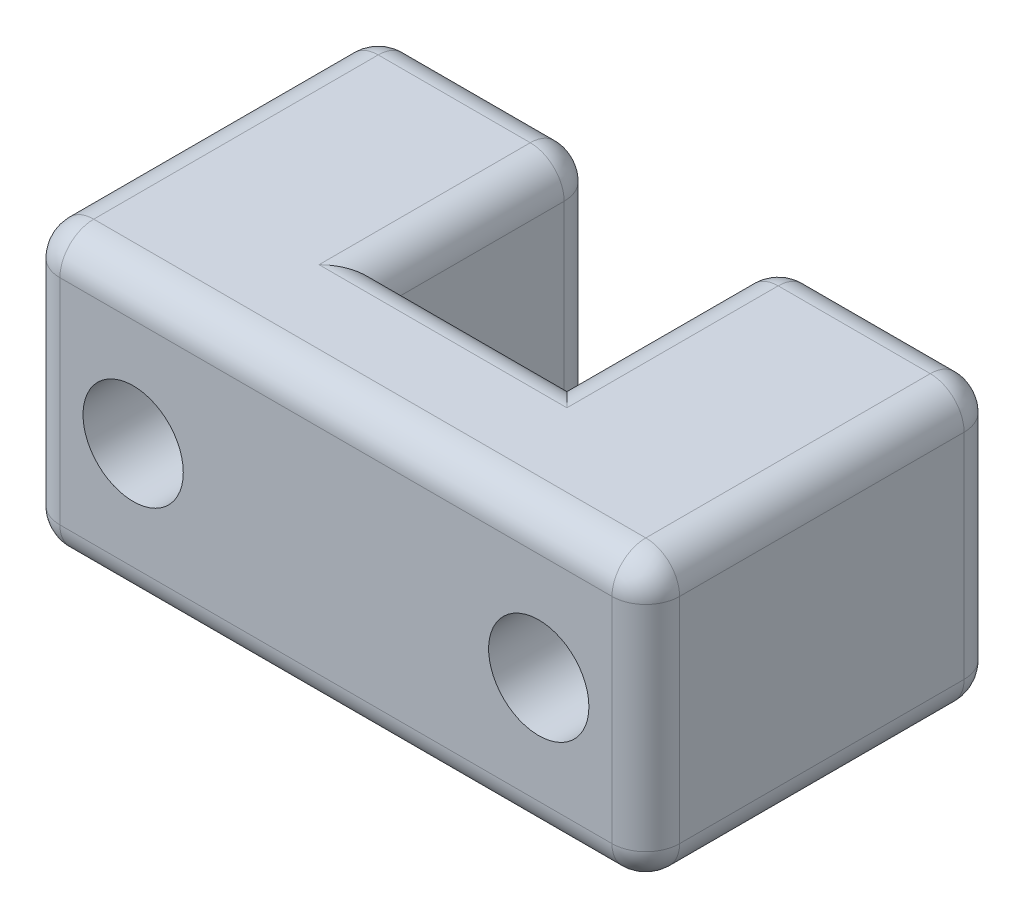
from build123d import *

# Parameters (mm, degrees)
BOSS_EXTRUDE1_DEPTH = 6.35
SKETCH2_R           = 1.1303
CUT_EXTRUDE1_DEPTH  = 7.9375
FILLET1_R           = 0.762


with BuildPart() as part:
    # Sketch1 → Boss-Extrude1 (new body)
    with BuildSketch(Plane(origin=(0, 0, 0), x_dir=(1, 0, 0), z_dir=(0, 1, 0))):
        Polygon((0, 7.9375), (4.953, 7.9375), (4.953, 3.175), (9.017, 3.175), (9.017, 7.9375), (13.97, 7.9375), (13.97, 0), (0, 0), align=None)
    extrude(amount=BOSS_EXTRUDE1_DEPTH)

    # Sketch2 → Cut-Extrude1 (cut)
    with BuildSketch(Plane.XY):
        with Locations((2.413, 3.175)):
            Circle(SKETCH2_R)
        with Locations((11.557, 3.175)):
            Circle(SKETCH2_R)
    extrude(amount=-CUT_EXTRUDE1_DEPTH, mode=Mode.SUBTRACT)

    # Fillet1
    fillet1_edges = [part.edges().sort_by_distance(p)[0] for p in [
        (13.97, 6.35, -3.96875),
        (6.985, 0, 0),
        (0, 0, -3.96875),
        (11.4935, 6.35, -7.9375),
        (0, 3.175, -7.9375),
        (4.953, 3.175, -7.9375),
        (9.017, 3.175, -7.9375),
        (13.97, 3.175, -7.9375),
        (13.97, 3.175, 0),
        (0, 3.175, 0),
        (9.017, 6.35, -5.55625),
        (6.985, 6.35, -3.175),
        (4.953, 6.35, -5.55625),
        (2.4765, 6.35, -7.9375),
        (0, 6.35, -3.96875),
        (6.985, 6.35, 0),
        (2.4765, 0, -7.9375),
        (4.953, 0, -5.55625),
        (6.985, 0, -3.175),
        (9.017, 0, -5.55625),
        (11.4935, 0, -7.9375),
        (13.97, 0, -3.96875),
    ]]
    fillet(fillet1_edges, radius=FILLET1_R)


solid = part.part
